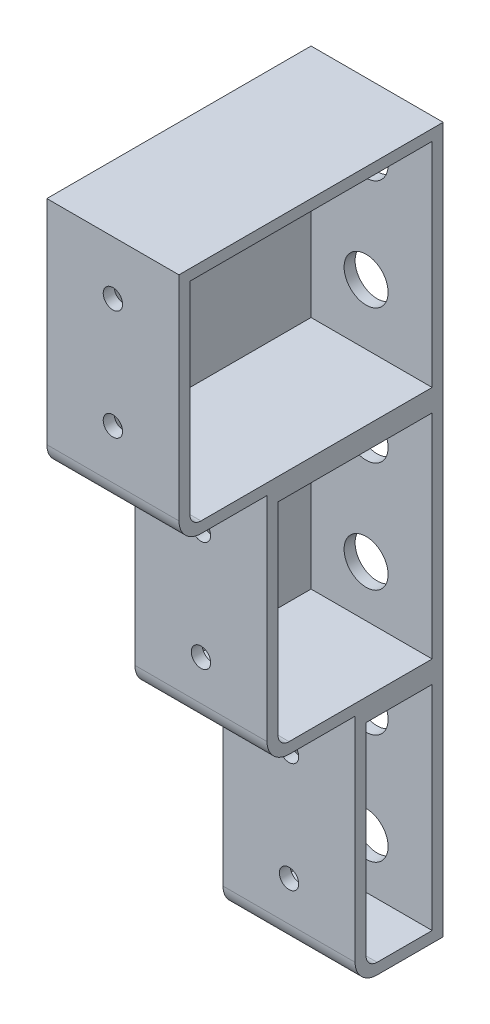
from build123d import *

# Parameters (mm, degrees)
BOSS_EXTRUDE1_DEPTH     = 19.05
CUT_EXTRUDE1_DEPTH      = 1
CUT_EXTRUDE1_DEPTH_BACK = 34.925
SKETCH4_R               = 2.794
CUT_EXTRUDE2_DEPTH      = 51.8
CUT_EXTRUDE2_DEPTH_BACK = 26.4
SKETCH5_R               = 2.794
CUT_EXTRUDE3_DEPTH      = 26.4
CUT_EXTRUDE3_DEPTH_BACK = 51.8
SKETCH6_R               = 2.794
CUT_EXTRUDE4_DEPTH      = 1
CUT_EXTRUDE4_DEPTH_BACK = 77.2
SKETCH7_R               = 6.35
CUT_EXTRUDE6_DEPTH      = 34.925


with BuildPart() as part:
    # Sketch1 → Boss-Extrude1 (new body, symmetric)
    with BuildSketch(Plane.YZ):
        with BuildLine():
            Line((6.35, 25.4), (67.818, 25.4))
            Line((67.818, 25.4), (67.818, 44.45))
            ThreePointArc((67.818, 44.45), (69.677871939, 48.940128061), (74.168, 50.8))
            Line((74.168, 50.8), (135.636, 50.8))
            Line((135.636, 50.8), (135.636, 69.85))
            ThreePointArc((135.636, 69.85), (137.495871939, 74.340128061), (141.986, 76.2))
            Line((141.986, 76.2), (203.454, 76.2))
            Line((203.454, 76.2), (203.454, 0))
            Line((203.454, 0), (112.272540658, 0))
            Line((112.272540658, 0), (108.743815039, 0))
            Line((108.743815039, 0), (0, 0))
            Line((0, 0), (0, 19.05))
            ThreePointArc((0, 19.05), (1.859871939, 23.540128061), (6.35, 25.4))
        make_face()
    extrude(amount=BOSS_EXTRUDE1_DEPTH, both=True)

    # Sketch2 → Cut-Extrude1 (cut, two sides)
    with BuildSketch(Plane.YZ.offset(19.05)) as cut_extrude1_sk:
        with BuildLine():
            Line((6.35, 22.225), (64.643, 22.225))
            Line((64.643, 22.225), (64.643, 3.175))
            Line((64.643, 3.175), (3.175, 3.175))
            Line((3.175, 3.175), (3.175, 19.05))
            ThreePointArc((3.175, 19.05), (4.10493597, 21.29506403), (6.35, 22.225))
        make_face()
        with BuildLine():
            Line((74.168, 47.625), (132.461, 47.625))
            Line((132.461, 47.625), (132.461, 3.175))
            Line((132.461, 3.175), (70.993, 3.175))
            Line((70.993, 3.175), (70.993, 44.45))
            ThreePointArc((70.993, 44.45), (71.92293597, 46.69506403), (74.168, 47.625))
        make_face()
        with BuildLine():
            Line((141.986, 73.025), (200.279, 73.025))
            Line((200.279, 73.025), (200.279, 3.175))
            Line((200.279, 3.175), (138.811, 3.175))
            Line((138.811, 3.175), (138.811, 69.85))
            ThreePointArc((138.811, 69.85), (139.74093597, 72.09506403), (141.986, 73.025))
        make_face()
    extrude(amount=CUT_EXTRUDE1_DEPTH, mode=Mode.SUBTRACT)
    extrude(cut_extrude1_sk.sketch, amount=-CUT_EXTRUDE1_DEPTH_BACK, mode=Mode.SUBTRACT)

    # Sketch4 → Cut-Extrude2 (cut, two sides)
    with BuildSketch(Plane.XY.offset(25.4)) as cut_extrude2_sk:
        with Locations((0, 17.78)):
            Circle(SKETCH4_R)
        with Locations((0, 49.53)):
            Circle(SKETCH4_R)
    extrude(amount=CUT_EXTRUDE2_DEPTH, mode=Mode.SUBTRACT)
    extrude(cut_extrude2_sk.sketch, amount=-CUT_EXTRUDE2_DEPTH_BACK, mode=Mode.SUBTRACT)

    # Sketch5 → Cut-Extrude3 (cut, two sides)
    with BuildSketch(Plane.XY.offset(50.8)) as cut_extrude3_sk:
        with Locations((0, 85.725)):
            Circle(SKETCH5_R)
        with Locations((0, 117.475)):
            Circle(SKETCH5_R)
    extrude(amount=CUT_EXTRUDE3_DEPTH, mode=Mode.SUBTRACT)
    extrude(cut_extrude3_sk.sketch, amount=-CUT_EXTRUDE3_DEPTH_BACK, mode=Mode.SUBTRACT)

    # Sketch6 → Cut-Extrude4 (cut, two sides)
    with BuildSketch(Plane.XY.offset(76.2)) as cut_extrude4_sk:
        with Locations((0, 156.21)):
            Circle(SKETCH6_R)
        with Locations((0, 187.96)):
            Circle(SKETCH6_R)
    extrude(amount=CUT_EXTRUDE4_DEPTH, mode=Mode.SUBTRACT)
    extrude(cut_extrude4_sk.sketch, amount=-CUT_EXTRUDE4_DEPTH_BACK, mode=Mode.SUBTRACT)

    # Sketch7 → Cut-Extrude6 (cut)
    with BuildSketch(Plane.XY.offset(3.175)):
        with Locations((0, 17.78)):
            Circle(SKETCH7_R)
        with Locations((0, 49.53)):
            Circle(SKETCH7_R)
        with Locations((0, 85.725)):
            Circle(SKETCH7_R)
        with Locations((0, 117.475)):
            Circle(SKETCH7_R)
        with Locations((0, 156.21)):
            Circle(SKETCH7_R)
        with Locations((0, 187.96)):
            Circle(SKETCH7_R)
    extrude(amount=-CUT_EXTRUDE6_DEPTH, mode=Mode.SUBTRACT)


solid = part.part
